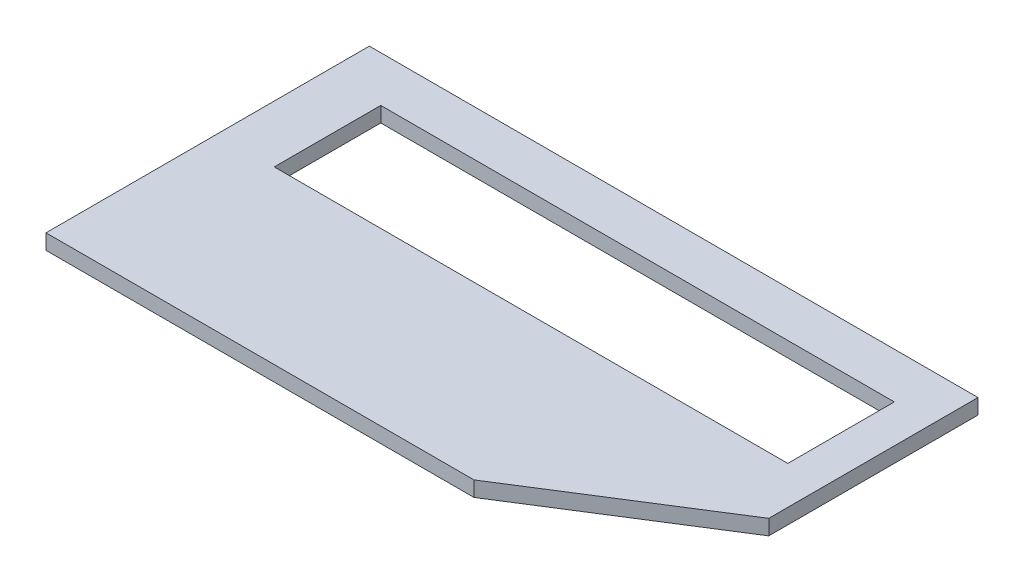
from build123d import *

# Parameters (mm, degrees)
SKETCH_1_W      = 270
SKETCH_1_H      = 56
EXTRUDE_1_DEPTH = 8


with BuildPart() as part:
    # Эскиз1 → Бобышка-Вытянуть1 (new body)
    with BuildSketch(Plane(origin=(0, 0, 0), x_dir=(1, 0, 0), z_dir=(0, 1, 0))):
        Polygon((320, 170), (320, 60), (225, 0), (0, 0), (0, 170), align=None)
        with Locations((165, 118)):
            Rectangle(SKETCH_1_W, SKETCH_1_H, mode=Mode.SUBTRACT)
    extrude(amount=EXTRUDE_1_DEPTH)


solid = part.part
